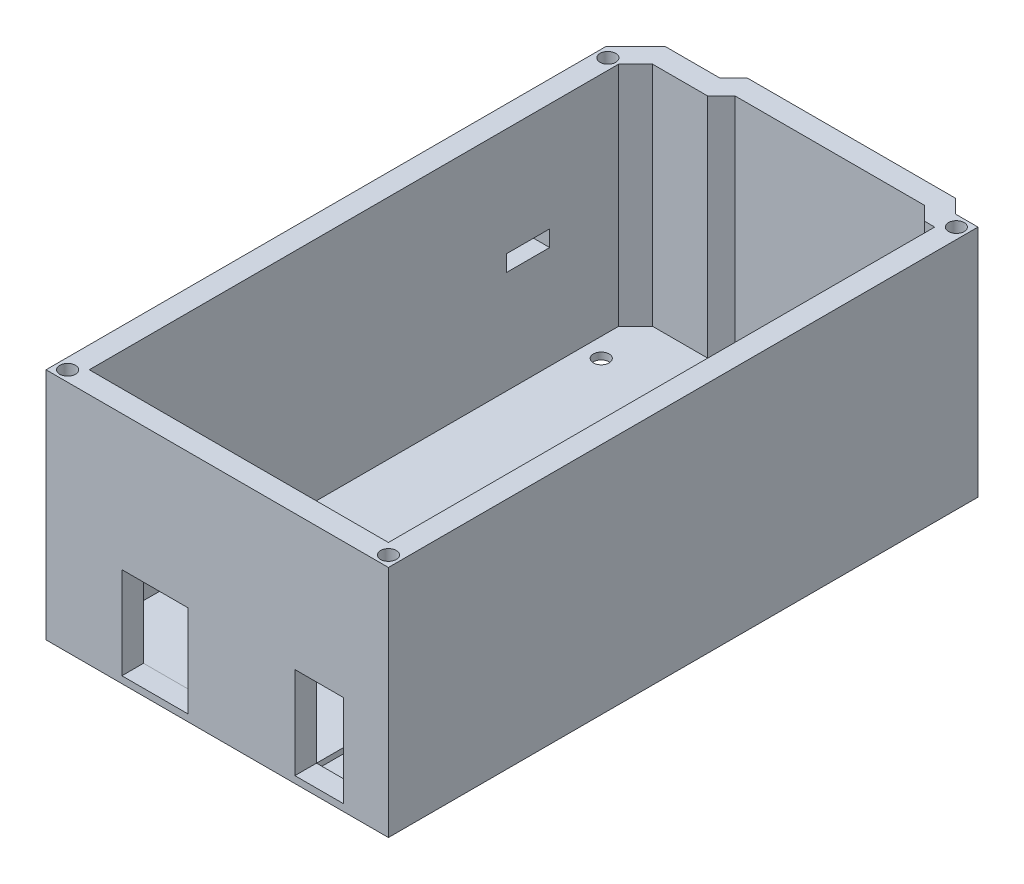
from build123d import *

# Parameters (mm, degrees)
SKETCH2_R           = 1.45
BOSS_EXTRUDE1_DEPTH = 1.27
BOSS_EXTRUDE2_DEPTH = 1.27
BOSS_EXTRUDE3_DEPTH = 18.27
SKETCH5_W           = 12.2
SKETCH5_H           = 4
SKETCH5_W_2         = 9
CUT_EXTRUDE1_DEPTH  = 17
BOSS_EXTRUDE4_DEPTH = 25
SKETCH7_R           = 1.45
CUT_EXTRUDE2_DEPTH  = 12
SKETCH8_W           = 8
SKETCH8_H           = 3
CUT_EXTRUDE3_DEPTH  = 4
SKETCH9_W           = 11.827328024
SKETCH9_H           = 14.418956252
CUT_EXTRUDE4_DEPTH  = 1


with BuildPart() as part:
    # Sketch2 → Boss-Extrude1 (new body)
    with BuildSketch(Plane(origin=(0, 0, 0), x_dir=(1, 0, 0), z_dir=(0, 1, 0))):
        Polygon((52.07, 99.06), (49.53, 101.6), (15.24, 101.6), (12.7, 99.06), (2.54, 99.06), (0, 96.52), (0, 0), (53.34, 0), (53.34, 99.06), align=None)
        with Locations((50.8, 13.97)):
            Circle(SKETCH2_R, mode=Mode.SUBTRACT)
        with Locations((2.54, 15.24)):
            Circle(SKETCH2_R, mode=Mode.SUBTRACT)
        with Locations((50.8, 96.52)):
            Circle(SKETCH2_R, mode=Mode.SUBTRACT)
        with Locations((2.54, 90.17)):
            Circle(SKETCH2_R, mode=Mode.SUBTRACT)
    extrude(amount=BOSS_EXTRUDE1_DEPTH)

    # Sketch3 → Boss-Extrude2 (add)
    with BuildSketch(Plane.XZ):
        Polygon((49.944213562, -102.6), (52.484213562, -100.06), (54.34, -100.06), (54.34, 1), (-1, 1), (-1, -96.934213562), (2.125786438, -100.06), (12.285786438, -100.06), (14.825786438, -102.6), align=None)
        Polygon((0, 0), (0, -96.52), (2.54, -99.06), (12.7, -99.06), (15.24, -101.6), (49.53, -101.6), (52.07, -99.06), (53.34, -99.06), (53.34, 0), align=None, mode=Mode.SUBTRACT)
    extrude(amount=-BOSS_EXTRUDE2_DEPTH)

    # Sketch9 → Cut-Extrude4 (cut)
    with BuildSketch(Plane(origin=(0, 1.27, 0), x_dir=(1, 0, 0), z_dir=(0, 1, 0))):
        with Locations((46.953664012, 6.209478126)):
            Rectangle(SKETCH9_W, SKETCH9_H)
    extrude(amount=-CUT_EXTRUDE4_DEPTH, mode=Mode.SUBTRACT)


with BuildPart() as body_2:
    # Sketch4 → Boss-Extrude3 (new body)
    with BuildSketch(Plane.XZ):
        Polygon((-5, 5), (-5, -98.591067812), (0.468932188, -104.06), (10.628932188, -104.06), (13.168932188, -106.6), (51.601067812, -106.6), (54.141067812, -104.06), (58.34, -104.06), (58.34, 5), align=None)
        Polygon((14.825786438, -102.6), (49.944213562, -102.6), (52.484213562, -100.06), (54.34, -100.06), (54.34, 1), (-1, 1), (-1, -96.934213562), (2.125786438, -100.06), (12.285786438, -100.06), align=None, mode=Mode.SUBTRACT)
    extrude(amount=-BOSS_EXTRUDE3_DEPTH)

    # Sketch5 → Cut-Extrude1 (cut)
    with BuildSketch(Plane(origin=(0, 18.27, 0), x_dir=(1, 0, 0), z_dir=(0, 1, 0))):
        with Locations((15.14, -3)):
            Rectangle(SKETCH5_W, SKETCH5_H)
        with Locations((45.54, -3)):
            Rectangle(SKETCH5_W_2, SKETCH5_H)
    extrude(amount=-CUT_EXTRUDE1_DEPTH, mode=Mode.SUBTRACT)

    # Sketch6 → Boss-Extrude4 (add)
    with BuildSketch(Plane(origin=(0, 18.27, 0), x_dir=(1, 0, 0), z_dir=(0, 1, 0))):
        Polygon((9.04, -5), (50.04, -5), (58.34, -5), (58.34, 104.06), (54.141067812, 104.06), (51.601067812, 106.6), (13.168932188, 106.6), (10.628932188, 104.06), (0.468932188, 104.06), (-5, 98.591067812), (-5, -5), align=None)
        Polygon((9.04, -1), (50.04, -1), (54.34, -1), (54.34, 100.06), (52.484213562, 100.06), (49.944213562, 102.6), (14.825786438, 102.6), (12.285786438, 100.06), (2.125786438, 100.06), (-1, 96.934213562), (-1, -1), align=None, mode=Mode.SUBTRACT)
    extrude(amount=BOSS_EXTRUDE4_DEPTH)

    # Sketch7 → Cut-Extrude2 (cut)
    with BuildSketch(Plane(origin=(0, 43.27, 0), x_dir=(1, 0, 0), z_dir=(0, 1, 0))):
        with Locations((-3, -3)):
            Circle(SKETCH7_R)
        with Locations((56.34, -3)):
            Circle(SKETCH7_R)
        with Locations((56.34, 102.06)):
            Circle(SKETCH7_R)
        with Locations((-3, 96.934213562)):
            Circle(SKETCH7_R)
    extrude(amount=-CUT_EXTRUDE2_DEPTH, mode=Mode.SUBTRACT)

    # Sketch8 → Cut-Extrude3 (cut)
    with BuildSketch(Plane.ZY.offset(5)):
        with Locations((-80.173407403, 21.762666212)):
            Rectangle(SKETCH8_W, SKETCH8_H)
    extrude(amount=-CUT_EXTRUDE3_DEPTH, mode=Mode.SUBTRACT)


solid = Compound([part.part, body_2.part])
